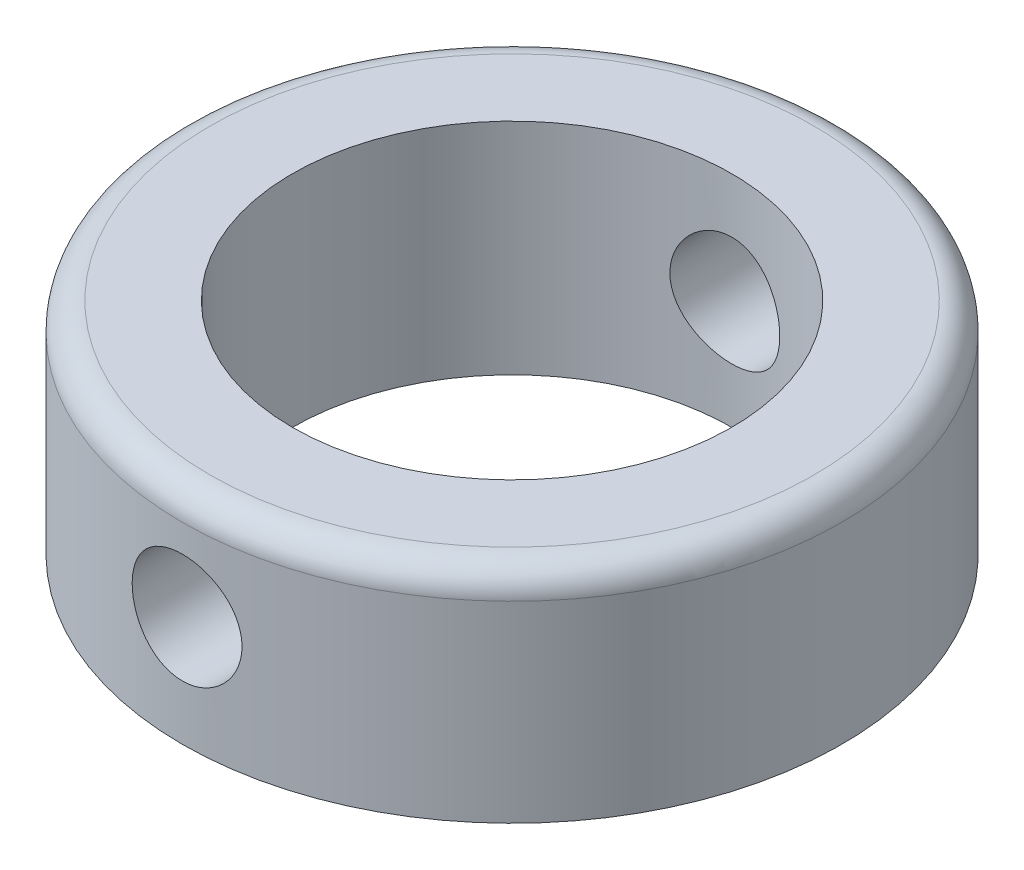
from build123d import *

# Parameters (mm, degrees)
SKETCH1_R           = 12
SKETCH1_R_2         = 8
BOSS_EXTRUDE1_DEPTH = 4
FILLET1_R           = 1
SKETCH2_R           = 2
CUT_EXTRUDE1_DEPTH  = 25


with BuildPart() as part:
    # Sketch1 → Boss-Extrude1 (new body, symmetric)
    with BuildSketch(Plane(origin=(0, 0, 0), x_dir=(1, 0, 0), z_dir=(0, 1, 0))):
        Circle(SKETCH1_R)
        Circle(SKETCH1_R_2, mode=Mode.SUBTRACT)
    extrude(amount=BOSS_EXTRUDE1_DEPTH, both=True)

    # Fillet1
    fillet1_edges = [part.edges().sort_by_distance(p)[0] for p in [
        (-12, 4, 0),
    ]]
    fillet(fillet1_edges, radius=FILLET1_R)

    # Sketch2 → Cut-Extrude1 (cut, symmetric)
    with BuildSketch(Plane.XY):
        Circle(SKETCH2_R)
    extrude(amount=CUT_EXTRUDE1_DEPTH, both=True, mode=Mode.SUBTRACT)


solid = part.part
